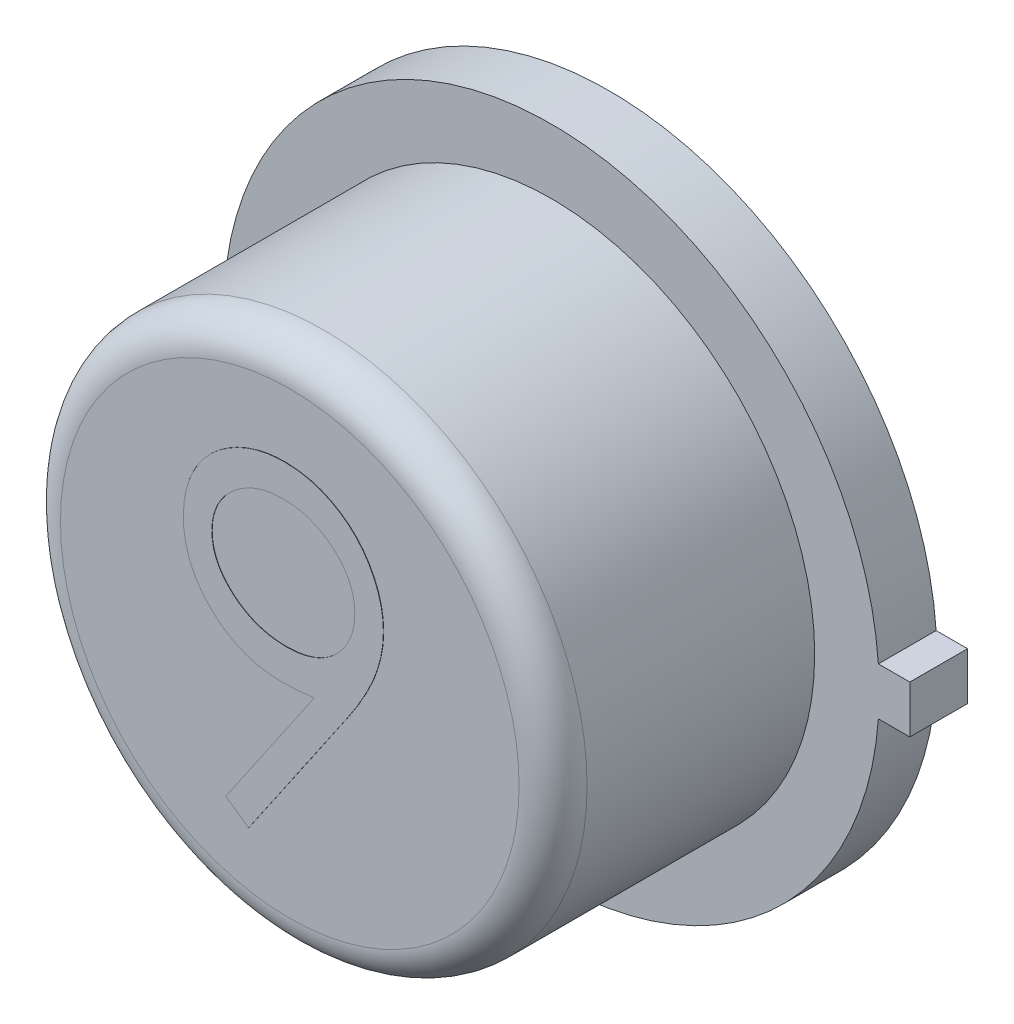
from build123d import *

# Parameters (mm, degrees)
BOSS_EXTRUDE1_DEPTH = 0.4318
SKETCH2_R           = 1.9685
BOSS_EXTRUDE2_DEPTH = 1.9558
SKETCH3_R           = 1.757566481
BOSS_EXTRUDE3_DEPTH = 0.00254
FILLET1_R           = 0.254
BOSS_EXTRUDE6_DEPTH = 0.00254


with BuildPart() as part:
    # Sketch1 → Boss-Extrude1 (new body)
    with BuildSketch(Plane.XY):
        with BuildLine():
            Line((2.6797, 0.1778), (2.4511, 0.1778))
            Line((2.4511, 0.1778), (2.44464279, 0.1778))
            ThreePointArc((2.44464279, 0.1778), (-2.4511, 0), (2.44464279, -0.1778))
            Line((2.44464279, -0.1778), (2.4511, -0.1778))
            Line((2.4511, -0.1778), (2.6797, -0.1778))
            Line((2.6797, -0.1778), (2.6797, 0.1778))
        make_face()
    extrude(amount=BOSS_EXTRUDE1_DEPTH)

    # Sketch2 → Boss-Extrude2 (add)
    with BuildSketch(Plane.XY.offset(0.4318)):
        Circle(SKETCH2_R)
    extrude(amount=BOSS_EXTRUDE2_DEPTH)

    # Sketch3 → Boss-Extrude3 (add)
    with BuildSketch(Plane(origin=(0, 0, 0), x_dir=(-1, 0, 0), z_dir=(0, 0, -1))):
        Circle(SKETCH3_R)
    extrude(amount=BOSS_EXTRUDE3_DEPTH)

    # Fillet1
    fillet1_edges = [part.edges().sort_by_distance(p)[0] for p in [
        (-1.9685, 0, 2.3876),
    ]]
    fillet(fillet1_edges, radius=FILLET1_R)

    # Sketch4 → Boss-Extrude6 (add)
    with BuildSketch(Plane.XY.offset(2.3876)):
        with BuildLine():
            Line((-0.305288462, -1.279198899), (-0.476059195, -1.160422607))
            Line((-0.476059195, -1.160422607), (0.186035156, -0.192562781))
            add(Edge.make_bspline(
                [(0.186035156, -0.192562781), (0.143791281, -0.197728776), (0.060610735, -0.207900908), (-0.023166472, -0.209769614), (-0.064396785, -0.210689284)],
                knots=[0, 0, 0, 0, 0.000127587, 0.000251225, 0.000251225, 0.000251225, 0.000251225], degree=3))
            add(Edge.make_bspline(
                [(-0.064396785, -0.210689284), (-0.0893945, -0.210049016), (-0.138462827, -0.208792225), (-0.21060222, -0.198830567), (-0.279920788, -0.183488426), (-0.346234761, -0.160595255), (-0.409793388, -0.132143938), (-0.470457918, -0.096862648), (-0.528146687, -0.055356582), (-0.582240121, -0.007845208), (-0.631437929, 0.044323253), (-0.67526878, 0.099538074), (-0.711695871, 0.158440655), (-0.741955834, 0.219829429), (-0.764904589, 0.284586741), (-0.781615887, 0.351975708), (-0.791904489, 0.422468628), (-0.793128516, 0.470450905), (-0.79375, 0.49481327)],
                knots=[0, 0, 0, 0, 7.4965e-05, 0.000147151, 0.000218086, 0.000287627, 0.000357227, 0.000426689, 0.000497779, 0.000570115, 0.000642325, 0.000712654, 0.000781218, 0.000849699, 0.000917596, 0.000986896, 0.001057728, 0.001130788, 0.001130788, 0.001130788, 0.001130788], degree=3))
            add(Edge.make_bspline(
                [(-0.79375, 0.49481327), (-0.792569965, 0.528129443), (-0.790253795, 0.593522331), (-0.771613018, 0.689067449), (-0.740955895, 0.779409723), (-0.69821016, 0.864311622), (-0.644370287, 0.942551836), (-0.579662478, 1.013042693), (-0.504480317, 1.074781603), (-0.420536479, 1.127852234), (-0.329808799, 1.170534438), (-0.23478423, 1.201993676), (-0.136190873, 1.220498538), (-0.069401797, 1.222938205), (-0.035775992, 1.224166485)],
                knots=[0, 0, 0, 0, 9.9888e-05, 0.000196061, 0.000290793, 0.000385297, 0.0004803, 0.00057483, 0.000671391, 0.000771305, 0.000872023, 0.000971431, 0.001070884, 0.001171725, 0.001171725, 0.001171725, 0.001171725], degree=3))
            add(Edge.make_bspline(
                [(-0.035775992, 1.224166485), (-0.002786549, 1.222921321), (0.06239748, 1.220460993), (0.158252322, 1.202442436), (0.250060407, 1.172073556), (0.3373128, 1.130106023), (0.418098007, 1.077500191), (0.490743693, 1.01481581), (0.553592051, 0.942013835), (0.606540084, 0.860855059), (0.649042022, 0.773655738), (0.679707272, 0.68263489), (0.698584215, 0.588447117), (0.700962966, 0.524633377), (0.702163462, 0.492428204)],
                knots=[0, 0, 0, 0, 9.8936e-05, 0.000195489, 0.000291427, 0.000388288, 0.000485136, 0.000579821, 0.000675178, 0.000772686, 0.000869756, 0.000965392, 0.001060159, 0.001156715, 0.001156715, 0.001156715, 0.001156715], degree=3))
            add(Edge.make_bspline(
                [(0.702163462, 0.492428204), (0.701361723, 0.46742932), (0.699735596, 0.416725336), (0.68834893, 0.339688263), (0.669013054, 0.261140195), (0.64707038, 0.194654609), (0.625889387, 0.139744039), (0.605954153, 0.096370196), (0.583834277, 0.050717372), (0.558035974, 0.003264273), (0.530303055, -0.046594024), (0.498966297, -0.098357443), (0.464740542, -0.152095447), (0.440363536, -0.188322484), (0.427880859, -0.206873178)],
                knots=[0, 0, 0, 0, 7.4988e-05, 0.000152095, 0.000233082, 0.000317405, 0.000361962, 0.000409573, 0.00046056, 0.000514125, 0.000571577, 0.000631706, 0.00069562, 0.000762696, 0.000762696, 0.000762696, 0.000762696], degree=3))
            Line((0.427880859, -0.206873178), (-0.305288462, -1.279198899))
        make_face()
        with BuildLine():
            add(Edge.make_bspline(
                [(-0.024804687, 0.033541485), (-0.005867617, 0.034058818), (0.030996421, 0.035065888), (0.085001333, 0.041195391), (0.13597655, 0.052063406), (0.18405824, 0.067656996), (0.229728507, 0.086473408), (0.272261937, 0.110430134), (0.311694128, 0.139016452), (0.348289128, 0.171136123), (0.380785706, 0.206821253), (0.409730161, 0.244170891), (0.434332262, 0.283348992), (0.453765491, 0.324846194), (0.46974339, 0.367652366), (0.48077743, 0.412456847), (0.486889985, 0.459026205), (0.487932003, 0.490661899), (0.488461538, 0.506738601)],
                knots=[0, 0, 0, 0, 5.6815e-05, 0.000110599, 0.000162805, 0.000212889, 0.000262059, 0.000310754, 0.000358941, 0.000407944, 0.000456557, 0.000503499, 0.000549562, 0.000595009, 0.000640735, 0.000686434, 0.000733118, 0.000781355, 0.000781355, 0.000781355, 0.000781355], degree=3))
            add(Edge.make_bspline(
                [(0.488461538, 0.506738601), (0.488005924, 0.522822016), (0.487108081, 0.554516358), (0.479904936, 0.601154663), (0.467233132, 0.645849543), (0.450230677, 0.688845685), (0.427833158, 0.729789831), (0.40095668, 0.769196029), (0.369025852, 0.806814423), (0.332284821, 0.841760277), (0.292664526, 0.873973758), (0.250441222, 0.902403213), (0.205962931, 0.926230134), (0.159501008, 0.945891755), (0.110958649, 0.961235017), (0.060364579, 0.972268616), (0.007463133, 0.978372614), (-0.028446992, 0.979408046), (-0.046747296, 0.979935716)],
                knots=[0, 0, 0, 0, 4.8237e-05, 9.5058e-05, 0.000141121, 0.000187359, 0.000233462, 0.000280828, 0.00033024, 0.000381182, 0.000432735, 0.000483274, 0.000533641, 0.000583875, 0.000634413, 0.000686153, 0.00073899, 0.000793898, 0.000793898, 0.000793898, 0.000793898], degree=3))
            add(Edge.make_bspline(
                [(-0.046747296, 0.979935716), (-0.064888443, 0.979407193), (-0.100481224, 0.978370235), (-0.152912376, 0.972280219), (-0.203164349, 0.961160813), (-0.251566058, 0.945898862), (-0.2980266, 0.926228668), (-0.342502794, 0.902401965), (-0.384735975, 0.873980302), (-0.424318283, 0.84173493), (-0.46112419, 0.806977085), (-0.492506024, 0.769031234), (-0.519444011, 0.729810329), (-0.541810754, 0.688840237), (-0.558821395, 0.645850996), (-0.571491007, 0.601154269), (-0.578694741, 0.554516461), (-0.579592504, 0.52282205), (-0.580048077, 0.506738601)],
                knots=[0, 0, 0, 0, 5.4432e-05, 0.000106795, 0.000158069, 0.000208607, 0.000258841, 0.000309208, 0.000359747, 0.0004113, 0.000462242, 0.000511347, 0.000558713, 0.000604816, 0.000651054, 0.000697117, 0.000743937, 0.000792175, 0.000792175, 0.000792175, 0.000792175], degree=3))
            add(Edge.make_bspline(
                [(-0.580048077, 0.506738601), (-0.579635831, 0.49064938), (-0.578822806, 0.458918491), (-0.570979792, 0.412296071), (-0.557863676, 0.367604639), (-0.54029727, 0.324409643), (-0.517164045, 0.283131111), (-0.488776927, 0.243964745), (-0.455503689, 0.206466555), (-0.41778912, 0.171219148), (-0.376513103, 0.138866686), (-0.332428174, 0.110611194), (-0.286293267, 0.086749406), (-0.237945979, 0.067603215), (-0.187744603, 0.052219208), (-0.135237951, 0.041215421), (-0.080599668, 0.035124682), (-0.043581448, 0.034074281), (-0.024804687, 0.033541485)],
                knots=[0, 0, 0, 0, 4.8237e-05, 9.5133e-05, 0.000141327, 0.000187744, 0.000234725, 0.000282913, 0.000332588, 0.000384897, 0.00043757, 0.000489704, 0.00054176, 0.000593136, 0.000645496, 0.000699103, 0.000753834, 0.000810173, 0.000810173, 0.000810173, 0.000810173], degree=3))
        make_face(mode=Mode.SUBTRACT)
    extrude(amount=BOSS_EXTRUDE6_DEPTH)


solid = part.part
